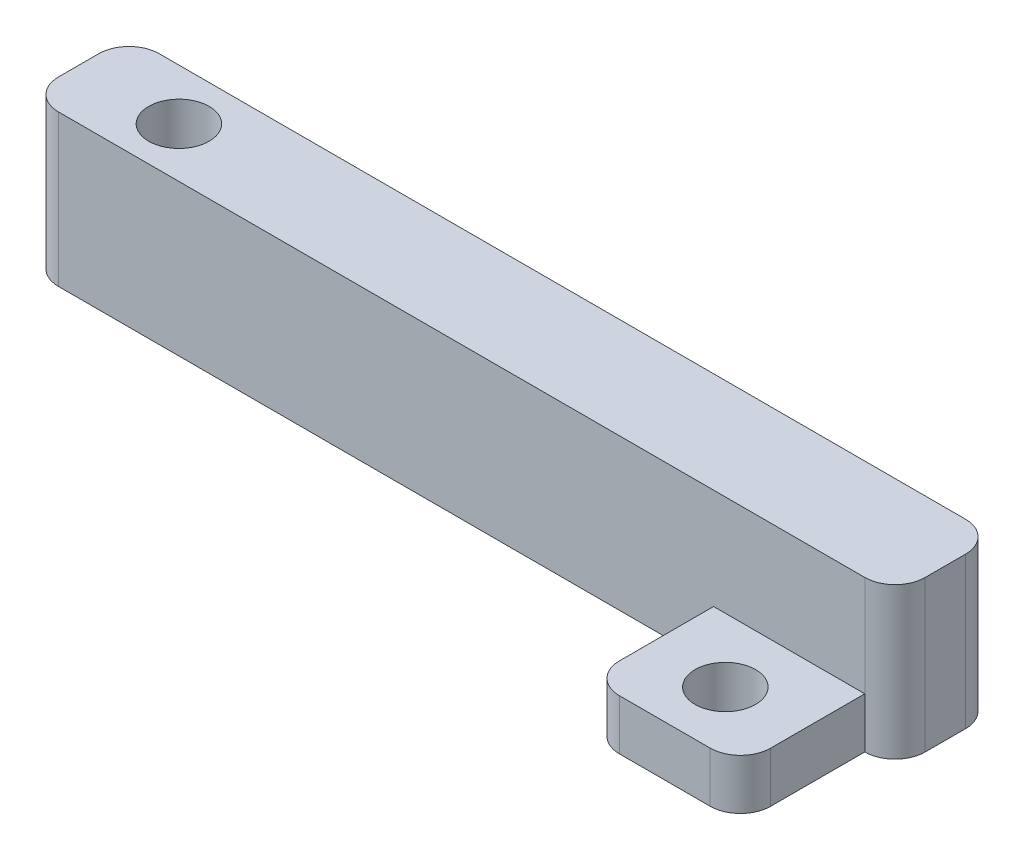
from build123d import *

# Parameters (mm, degrees)
SKETCH1_R           = 1.4
BOSS_EXTRUDE1_DEPTH = 15
SKETCH3_R           = 3
CUT_EXTRUDE2_DEPTH  = 3
SKETCH4_R           = 3
CUT_EXTRUDE3_DEPTH  = 10
BOSS_EXTRUDE2_DEPTH = 5
SKETCH7_R           = 3
CUT_EXTRUDE4_DEPTH  = 5


with BuildPart() as part:
    # Sketch1 → Boss-Extrude1 (new body)
    with BuildSketch(Plane(origin=(0, 0, 0), x_dir=(1, 0, 0), z_dir=(0, 1, 0))):
        with BuildLine():
            Line((-26.264799853, -4.189688425), (-26.264799853, -8.189688425))
            ThreePointArc((-26.264799853, -8.189688425), (-25.386120197, -10.311008768), (-23.264799853, -11.189688425))
            Line((-23.264799853, -11.189688425), (14.289498055, -11.189688425))
            Line((14.289498055, -11.189688425), (56.735200147, -11.189688425))
            ThreePointArc((56.735200147, -11.189688425), (58.85652049, -10.311008768), (59.735200147, -8.189688425))
            Line((59.735200147, -8.189688425), (59.735200147, -4.189688425))
            ThreePointArc((59.735200147, -4.189688425), (58.85652049, -2.068368081), (56.735200147, -1.189688425))
            Line((56.735200147, -1.189688425), (-23.264799853, -1.189688425))
            ThreePointArc((-23.264799853, -1.189688425), (-25.386120197, -2.068368081), (-26.264799853, -4.189688425))
        make_face()
        with Locations((-16.264799853, -6.238015415)):
            Circle(SKETCH1_R, mode=Mode.SUBTRACT)
    extrude(amount=BOSS_EXTRUDE1_DEPTH)

    # Sketch3 → Cut-Extrude2 (cut)
    with BuildSketch(Plane.XZ):
        with Locations((-16.264799853, 6.238015415)):
            Circle(SKETCH3_R)
    extrude(amount=-CUT_EXTRUDE2_DEPTH, mode=Mode.SUBTRACT)

    # Sketch4 → Cut-Extrude3 (cut)
    with BuildSketch(Plane(origin=(0, 15, 0), x_dir=(1, 0, 0), z_dir=(0, 1, 0))):
        with Locations((-16.264799853, -6.238015415)):
            Circle(SKETCH4_R)
    extrude(amount=-CUT_EXTRUDE3_DEPTH, mode=Mode.SUBTRACT)

    # Sketch5 → Boss-Extrude2 (add)
    with BuildSketch(Plane.XZ):
        with BuildLine():
            Line((56.735200147, 11.189688425), (41.735200147, 11.189688425))
            Line((41.735200147, 11.189688425), (41.735200147, 20.523996962))
            ThreePointArc((41.735200147, 20.523996962), (42.613879803, 22.645317306), (44.735200147, 23.523996962))
            Line((44.735200147, 23.523996962), (53.735200147, 23.523996962))
            ThreePointArc((53.735200147, 23.523996962), (55.85652049, 22.645317306), (56.735200147, 20.523996962))
            Line((56.735200147, 20.523996962), (56.735200147, 11.189688425))
        make_face()
    extrude(amount=-BOSS_EXTRUDE2_DEPTH)

    # Sketch7 → Cut-Extrude4 (cut)
    with BuildSketch(Plane(origin=(0, 5, 0), x_dir=(1, 0, 0), z_dir=(0, 1, 0))):
        with Locations((49.235200147, -17.523996962)):
            Circle(SKETCH7_R)
    extrude(amount=-CUT_EXTRUDE4_DEPTH, mode=Mode.SUBTRACT)


solid = part.part
